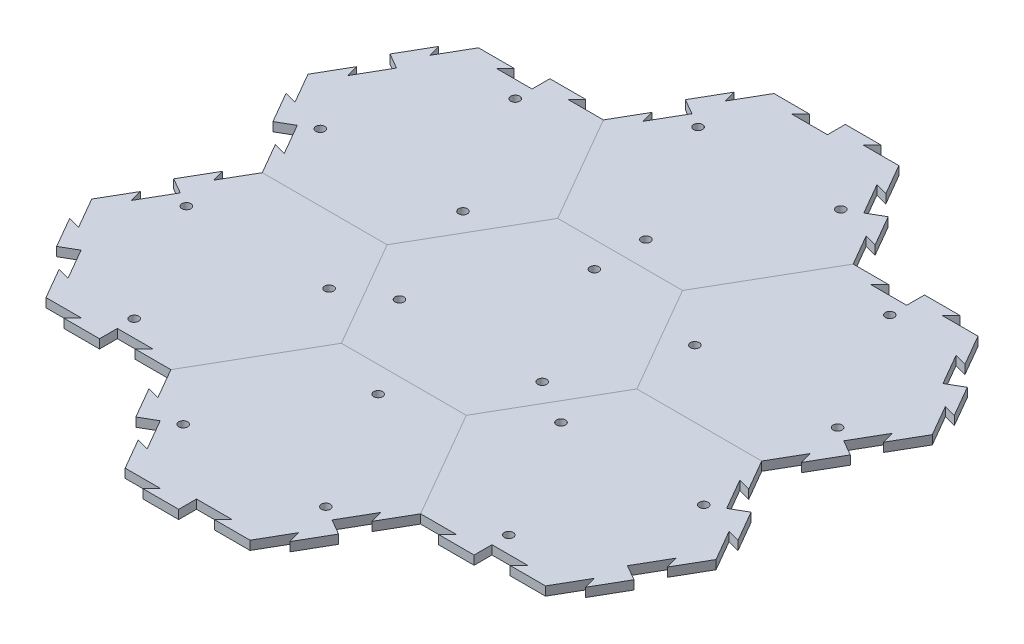
from build123d import *

# Parameters (mm, degrees)
BOSS_EXTRUDE1_DEPTH = 6.35
SKETCH9_R           = 3.175
CUT_EXTRUDE3_DEPTH  = 7.35
CIRPATTERN6_COUNT   = 3
CUT_EXTRUDE2_DEPTH  = 7.35
BOSS_EXTRUDE3_DEPTH = 6.35
CIRPATTERN3_COUNT   = 3
CIRPATTERN3_ANGLE   = 120
CIRPATTERN5_COUNT   = 6


with BuildPart() as part:
    # Sketch1 → Boss-Extrude1 (new body)
    with BuildSketch(Plane(origin=(0, 0, 0), x_dir=(1, 0, 0), z_dir=(0, 1, 0))):
        Polygon((88.9, 0), (44.45, 76.989658396), (-44.45, 76.989658396), (-88.9, 0), (-44.45, -76.989658396), (44.45, -76.989658396), align=None)
    extrude(amount=-BOSS_EXTRUDE1_DEPTH)

    # Sketch9 → Cut-Extrude3 (cut, through all)
    with BuildSketch(Plane(origin=(0, 0, 0), x_dir=(1, 0, 0), z_dir=(0, 1, 0))):
        with Locations((-50.8, -29.329393675)):
            Circle(SKETCH9_R)
    cut_extrude3 = extrude(amount=-CUT_EXTRUDE3_DEPTH, mode=Mode.SUBTRACT)

    # CirPattern6: Cut-Extrude3 ×3 about axis
    cirpattern6_axis = Axis((0, 0, 0), (0, 1, 0))
    for i in range(1, CIRPATTERN6_COUNT):
        add(cut_extrude3.rotate(cirpattern6_axis, i * 360 / CIRPATTERN6_COUNT), mode=Mode.SUBTRACT)


with BuildPart() as body_2:
    # Mirror1: mirrored copy
    add(part.part.mirror(Plane(origin=(44.45, -6.35, 76.989658396), x_dir=(-0.5, 0, 0.866025404), z_dir=(0.866025404, 0, 0.5))))

    # Sketch5 → Cut-Extrude2 (cut, through all)
    with BuildSketch(Plane(origin=(0, 0, 0), x_dir=(1, 0, 0), z_dir=(0, 1, 0))):
        Polygon((190.5, -21.997045256), (181.825738686, -19.672783942), (194.525738686, -41.669829198), (200.025, -38.494829198), align=None)
    cut_extrude2 = extrude(amount=-CUT_EXTRUDE2_DEPTH, mode=Mode.SUBTRACT)

    # Sketch7 → Boss-Extrude3 (add)
    with BuildSketch(Plane(origin=(0, 0, 0), x_dir=(1, 0, 0), z_dir=(0, 1, 0))):
        Polygon((200.025, -38.494829198), (205.524261314, -35.319829198), (218.224261314, -57.316874454), (209.55, -54.99261314), align=None)
    boss_extrude3 = extrude(amount=-BOSS_EXTRUDE3_DEPTH)

    # CirPattern3: Cut-Extrude2, Boss-Extrude3 ×3 about axis
    cirpattern3_axis = Axis((133.35, 0, 76.989658396), (0, -1, 0))
    for i in range(1, CIRPATTERN3_COUNT):
        add(cut_extrude2.rotate(cirpattern3_axis, i * CIRPATTERN3_ANGLE / (CIRPATTERN3_COUNT - 1)), mode=Mode.SUBTRACT)
        add(boss_extrude3.rotate(cirpattern3_axis, i * CIRPATTERN3_ANGLE / (CIRPATTERN3_COUNT - 1)))


with BuildPart() as cirpattern5_1:
    # CirPattern5: pattern copy
    add(body_2.part.rotate(Axis((0, 0, 0), (0, 1, 0)), 1 * 360 / CIRPATTERN5_COUNT))


with BuildPart() as cirpattern5_2:
    # CirPattern5: pattern copy
    add(body_2.part.rotate(Axis((0, 0, 0), (0, 1, 0)), 2 * 360 / CIRPATTERN5_COUNT))


with BuildPart() as cirpattern5_3:
    # CirPattern5: pattern copy
    add(body_2.part.rotate(Axis((0, 0, 0), (0, 1, 0)), 3 * 360 / CIRPATTERN5_COUNT))


with BuildPart() as cirpattern5_4:
    # CirPattern5: pattern copy
    add(body_2.part.rotate(Axis((0, 0, 0), (0, 1, 0)), 4 * 360 / CIRPATTERN5_COUNT))


with BuildPart() as cirpattern5_5:
    # CirPattern5: pattern copy
    add(body_2.part.rotate(Axis((0, 0, 0), (0, 1, 0)), 5 * 360 / CIRPATTERN5_COUNT))


solid = Compound([part.part, body_2.part, cirpattern5_1.part, cirpattern5_2.part, cirpattern5_3.part, cirpattern5_4.part, cirpattern5_5.part])
